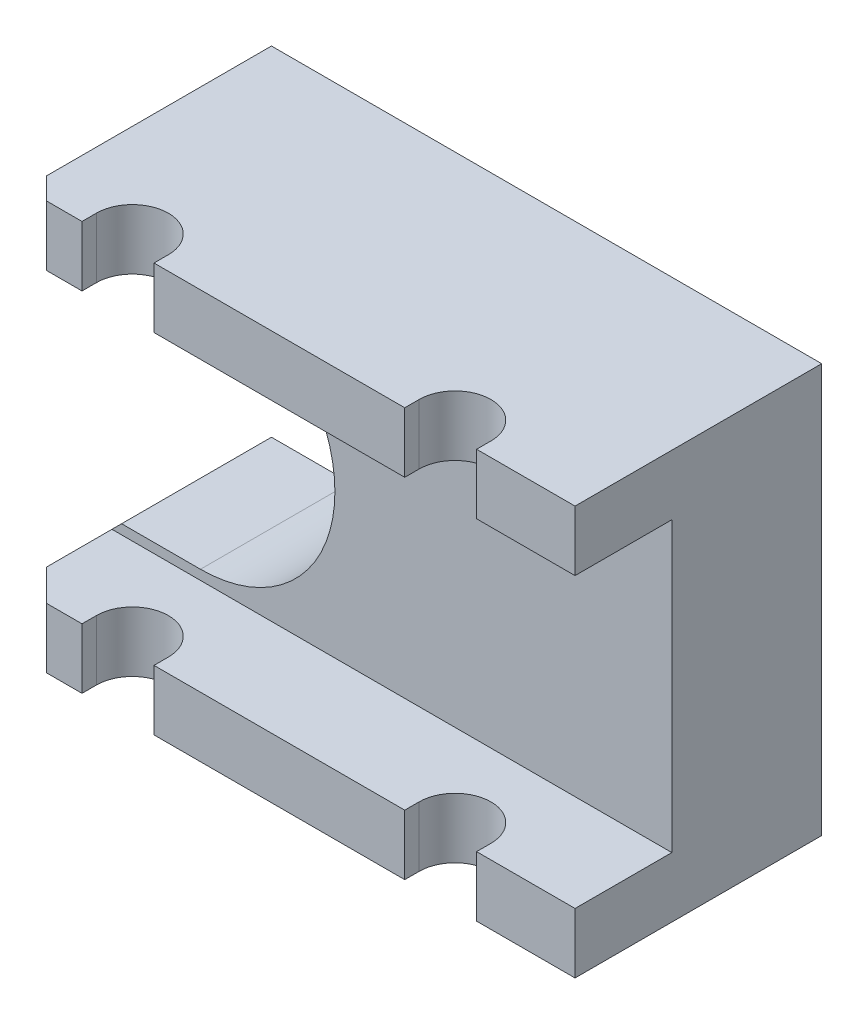
from build123d import *

# Parameters (mm, degrees)
EXTRUDE1_DEPTH                    = 36.195
SKETCH17_W                        = 99.9998
SKETCH17_H                        = 10.668
EXTRUDE4_DEPTH                    = 17.145
CUT_EXTRUDE2_DEPTH                = 73.39
SKETCH19_W                        = 99.9998
SKETCH19_H                        = 9.652
CUT_EXTRUDE3_DEPTH                = 86.2
F_1_4_20_TAPPED_HOLE1_D           = 5.1054
F_1_4_20_TAPPED_HOLE1_DEPTH       = 22.86
F_1_4_20_TAPPED_HOLE1_CBORE_D     = 6.35
F_1_4_20_TAPPED_HOLE1_CBORE_DEPTH = 19.05
F_1_4_20_TAPPED_HOLE1_TIP         = 1.533816902
CHAMFER1_SIZE                     = 2.54
SKETCH24_R                        = 3.9878
EXTRUDE5_DEPTH                    = 6.35
CHAMFER3_SIZE                     = 6.35


with BuildPart() as part:
    # Sketch5 → Extrude1 (new body)
    with BuildSketch(Plane.XY):
        with BuildLine():
            Line((48.9458, -36.195), (48.9458, 36.195))
            Line((48.9458, 36.195), (-51.054, 36.195))
            Line((-51.054, 36.195), (-51.054, 23.8125))
            Line((-51.054, 23.8125), (-34.544, 23.8125))
            ThreePointArc((-34.544, 23.8125), (-10.7315, 0), (-34.544, -23.8125))
            Line((-34.544, -23.8125), (-51.054, -23.8125))
            Line((-51.054, -23.8125), (-51.054, -36.195))
            Line((-51.054, -36.195), (48.9458, -36.195))
        make_face()
    extrude(amount=EXTRUDE1_DEPTH)

    # Sketch17 → Extrude4 (add)
    with BuildSketch(Plane.XY.offset(36.195)):
        with Locations((-1.0541, 30.861)):
            Rectangle(SKETCH17_W, SKETCH17_H)
        with Locations((-1.0541, -30.861)):
            Rectangle(SKETCH17_W, SKETCH17_H)
    extrude(amount=EXTRUDE4_DEPTH)

    # Sketch16 → Cut-Extrude2 (cut, through all)
    with BuildSketch(Plane.XZ.offset(36.195)):
        with BuildLine():
            Line((-25.6286, 50.8), (-25.6286, 53.34))
            Line((-25.6286, 53.34), (-38.3794, 53.34))
            Line((-38.3794, 53.34), (-38.3794, 50.8))
            ThreePointArc((-38.3794, 50.8), (-32.004, 44.4246), (-25.6286, 50.8))
        make_face()
        with BuildLine():
            Line((31.5087, 50.8), (31.5087, 53.34))
            Line((31.5087, 53.34), (18.7833, 53.34))
            Line((18.7833, 53.34), (18.7833, 50.8))
            ThreePointArc((18.7833, 50.8), (25.146, 44.4373), (31.5087, 50.8))
        make_face()
    extrude(amount=-CUT_EXTRUDE2_DEPTH, mode=Mode.SUBTRACT)

    # Sketch19 → Cut-Extrude3 (cut)
    with BuildSketch(Plane.XZ.offset(36.195)):
        with Locations((-1.0541, 4.826)):
            Rectangle(SKETCH19_W, SKETCH19_H)
    extrude(amount=-CUT_EXTRUDE3_DEPTH, mode=Mode.SUBTRACT)

    # 1_4-20 Tapped Hole1
    with Locations(Plane(origin=(0, 0, 9.652), x_dir=(-1, 0, 0), z_dir=(0, 0, -1))):
        with Locations((7.874, 26.9875), (7.874, -26.9875)):
            CounterBoreHole(F_1_4_20_TAPPED_HOLE1_D / 2, F_1_4_20_TAPPED_HOLE1_CBORE_D / 2, F_1_4_20_TAPPED_HOLE1_CBORE_DEPTH, depth=F_1_4_20_TAPPED_HOLE1_DEPTH)
            with Locations((0, 0, -(F_1_4_20_TAPPED_HOLE1_DEPTH + F_1_4_20_TAPPED_HOLE1_TIP / 2))):  # 118° drill point
                Cone(0, F_1_4_20_TAPPED_HOLE1_D / 2, F_1_4_20_TAPPED_HOLE1_TIP, mode=Mode.SUBTRACT)

    # Chamfer1
    chamfer1_edges = [part.edges().sort_by_distance(p)[0] for p in [
        (-51.054, -23.8125, 22.9235),
        (-51.054, 23.8125, 22.9235),
        (-51.054, -36.195, 31.496),
        (-51.054, 36.195, 31.496),
    ]]
    chamfer(chamfer1_edges, length=CHAMFER1_SIZE)

    # Sketch24 → Extrude5 (cut)
    with BuildSketch(Plane(origin=(0, 0, 9.652), x_dir=(-1, 0, 0), z_dir=(0, 0, -1))):
        with Locations((7.874, -26.9875)):
            Circle(SKETCH24_R)
        with Locations((7.874, 26.9875)):
            Circle(SKETCH24_R)
    extrude(amount=-EXTRUDE5_DEPTH, mode=Mode.SUBTRACT)

    # Chamfer3
    chamfer3_edges = [part.edges().sort_by_distance(p)[0] for p in [
        (-51.054, -30.00375, 53.34),
        (-51.054, 30.00375, 53.34),
    ]]
    chamfer(chamfer3_edges, length=CHAMFER3_SIZE)


solid = part.part
